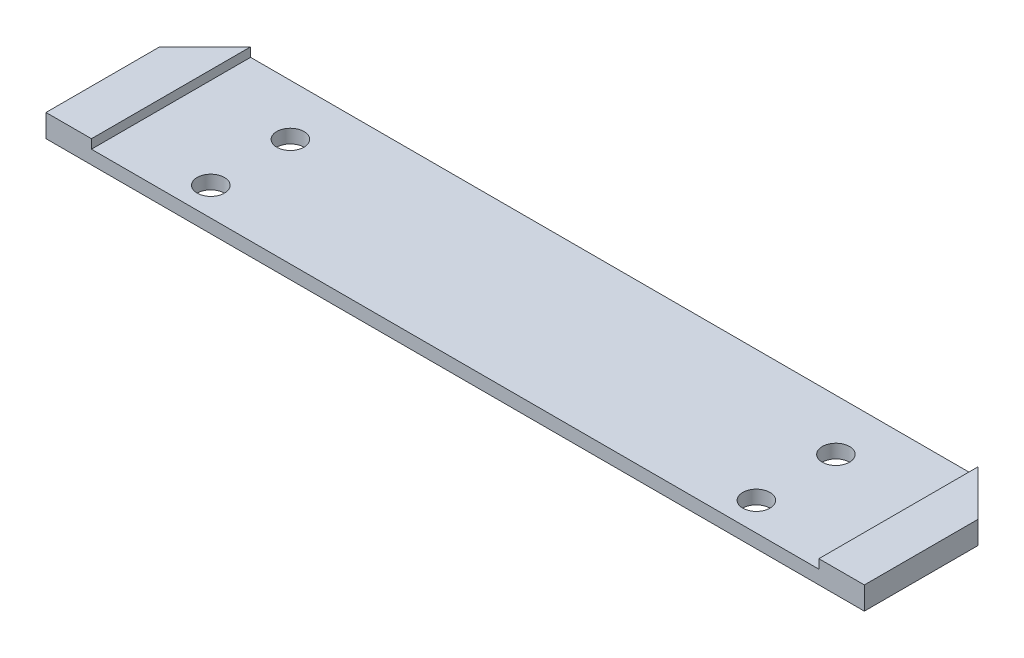
from build123d import *

# Parameters (mm, degrees)
SKETCH1_W             = 180
SKETCH1_H             = 35
BOSS_EXTRUDE1_DEPTH   = 5
F_6_0MM_DOWEL_HOLE1_D = 6
SKETCH4_W             = 160
SKETCH4_H             = 35
CUT_EXTRUDE1_DEPTH    = 2
CHAMFER1_SIZE         = 10


with BuildPart() as part:
    # Sketch1 → Boss-Extrude1 (new body)
    with BuildSketch(Plane(origin=(0, 0, 0), x_dir=(1, 0, 0), z_dir=(0, 1, 0))):
        Rectangle(SKETCH1_W, SKETCH1_H)
    extrude(amount=BOSS_EXTRUDE1_DEPTH)

    # Ø6.0mm Dowel Hole1 (through all)
    with Locations(Plane(origin=(-60, 5, -6.25), x_dir=(0, 0, 1), z_dir=(0, 1, 0))):
        with Locations((0, 0), (17.5, 0), (0, 120), (17.5, 120)):
            Hole(F_6_0MM_DOWEL_HOLE1_D / 2)

    # Sketch4 → Cut-Extrude1 (cut)
    with BuildSketch(Plane(origin=(0, 5, 0), x_dir=(1, 0, 0), z_dir=(0, 1, 0))):
        Rectangle(SKETCH4_W, SKETCH4_H)
    extrude(amount=-CUT_EXTRUDE1_DEPTH, mode=Mode.SUBTRACT)

    # Chamfer1
    chamfer1_edges = [part.edges().sort_by_distance(p)[0] for p in [
        (90, 2.5, -17.5),
        (-90, 2.5, -17.5),
    ]]
    chamfer(chamfer1_edges, length=CHAMFER1_SIZE)


solid = part.part
